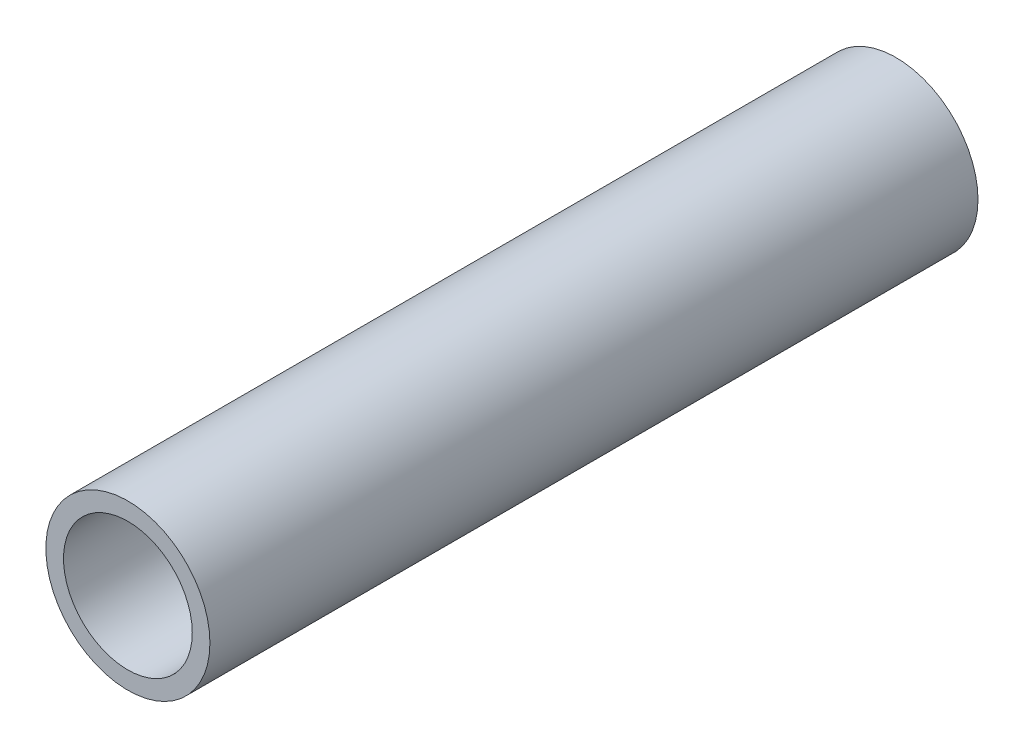
from build123d import *

# Parameters (mm, degrees)
SKETCH3_R                = 13.335
SKETCH3_R_2              = 10.4648
BOSS_EXTRUDE1_DEPTH      = 762
BOSS_EXTRUDE1_DEPTH_BACK = 762
SKETCH4_R                = 13.335
CUT_EXTRUDE2_DEPTH       = 1399.155469


with BuildPart() as part:
    # Sketch3 → Boss-Extrude1 (new body, two sides)
    with BuildSketch(Plane.XY) as boss_extrude1_sk:
        Circle(SKETCH3_R)
        Circle(SKETCH3_R_2, mode=Mode.SUBTRACT)
    extrude(amount=BOSS_EXTRUDE1_DEPTH)
    extrude(boss_extrude1_sk.sketch, amount=-BOSS_EXTRUDE1_DEPTH_BACK)

    # Sketch4 → Cut-Extrude2 (cut)
    with BuildSketch(Plane.XY.offset(762)):
        Circle(SKETCH4_R)
    extrude(amount=-CUT_EXTRUDE2_DEPTH, mode=Mode.SUBTRACT)


solid = part.part
